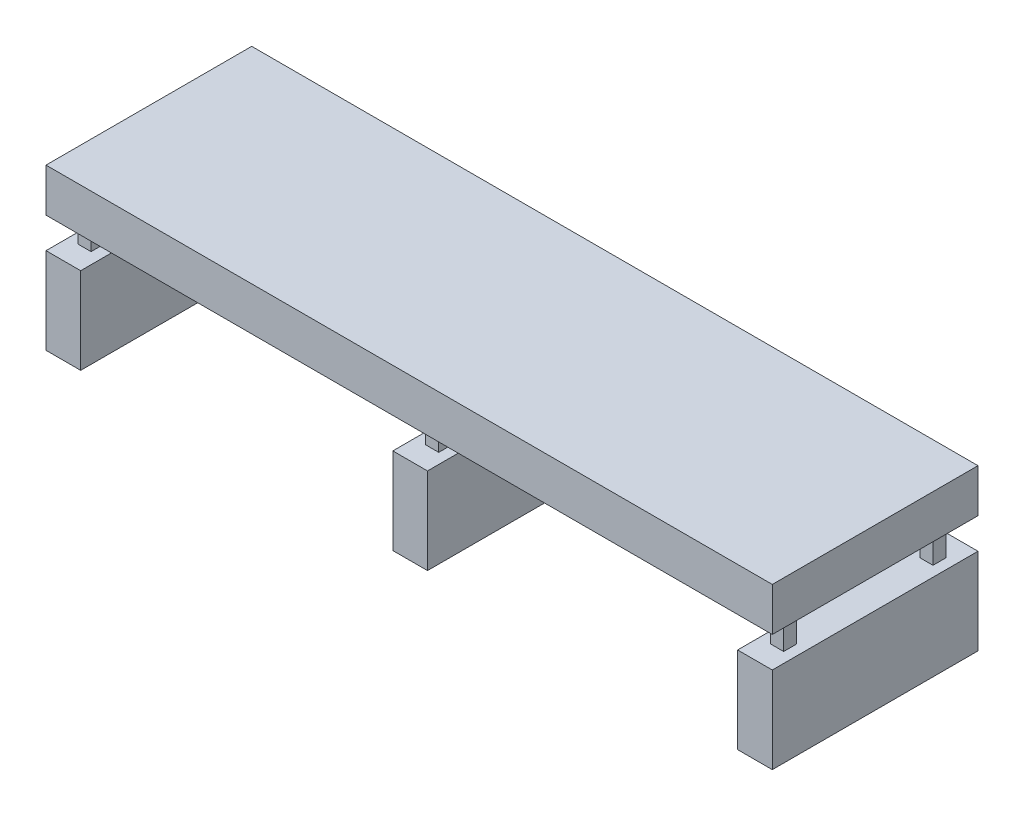
from build123d import *

# Parameters (mm, degrees)
SKETCH1_W           = 4254.5
SKETCH1_H           = 1204.9252
BOSS_EXTRUDE1_DEPTH = 939.8
SKETCH2_W           = 60.857687965
SKETCH2_H           = 180.116075376
SKETCH2_W_2         = 60.49310688
CUT_EXTRUDE1_DEPTH  = 1205.9252
SKETCH3_W           = 127
SKETCH3_H           = 180.116075376
SKETCH3_W_2         = 798.5252
CUT_EXTRUDE2_DEPTH  = 4255.5


with BuildPart() as part:
    # Sketch1 → Boss-Extrude1 (new body)
    with BuildSketch(Plane(origin=(0, 0, 0), x_dir=(1, 0, 0), z_dir=(0, 1, 0))):
        Rectangle(SKETCH1_W, SKETCH1_H)
    extrude(amount=BOSS_EXTRUDE1_DEPTH)

    # Sketch2 → Cut-Extrude1 (cut, through all)
    with BuildSketch(Plane.XY.offset(602.4626)):
        with Locations((-2096.821156018, 595.741962312)):
            Rectangle(SKETCH2_W, SKETCH2_H)
        Polygon((-29.977483529, 685.8), (-1990.192312035, 685.8), (-1990.192312035, 505.683924624), (-1924.05, 505.683924624), (-1924.05, 0), (-95.72476265, 0), (-95.72476265, 505.683924624), (-29.977483529, 505.683924624), align=None)
        Polygon((1990.55689312, 685.8), (46.222516471, 685.8), (46.222516471, 505.683924624), (107.47523735, 505.683924624), (107.47523735, 0), (1924.05, 0), (1924.05, 505.683924624), (1990.55689312, 505.683924624), align=None)
        with Locations((2097.00344656, 595.741962312)):
            Rectangle(SKETCH2_W_2, SKETCH2_H)
    extrude(amount=-CUT_EXTRUDE1_DEPTH, mode=Mode.SUBTRACT)

    # Sketch3 → Cut-Extrude2 (cut, through all)
    with BuildSketch(Plane.ZY.offset(2127.25)):
        with Locations((-538.9626, 595.741962312)):
            Rectangle(SKETCH3_W, SKETCH3_H)
        with Locations((0, 595.741962312)):
            Rectangle(SKETCH3_W_2, SKETCH3_H)
        with Locations((538.9626, 595.741962312)):
            Rectangle(SKETCH3_W, SKETCH3_H)
    extrude(amount=-CUT_EXTRUDE2_DEPTH, mode=Mode.SUBTRACT)


solid = part.part
